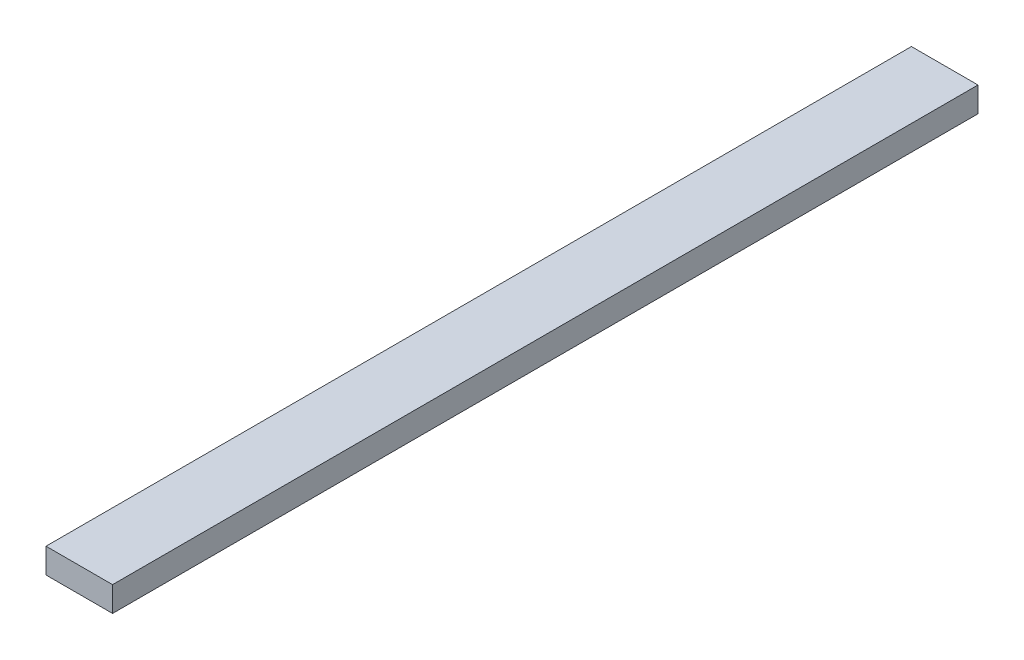
from build123d import *

# Parameters (mm, degrees)
SKETCH1_W           = 40
SKETCH1_H           = 520
BOSS_EXTRUDE2_DEPTH = 15


with BuildPart() as part:
    # Sketch1 → Boss-Extrude2 (new body)
    with BuildSketch(Plane(origin=(0, 0, 0), x_dir=(1, 0, 0), z_dir=(0, 1, 0))):
        with Locations((20, 260)):
            Rectangle(SKETCH1_W, SKETCH1_H)
    extrude(amount=BOSS_EXTRUDE2_DEPTH)


solid = part.part
